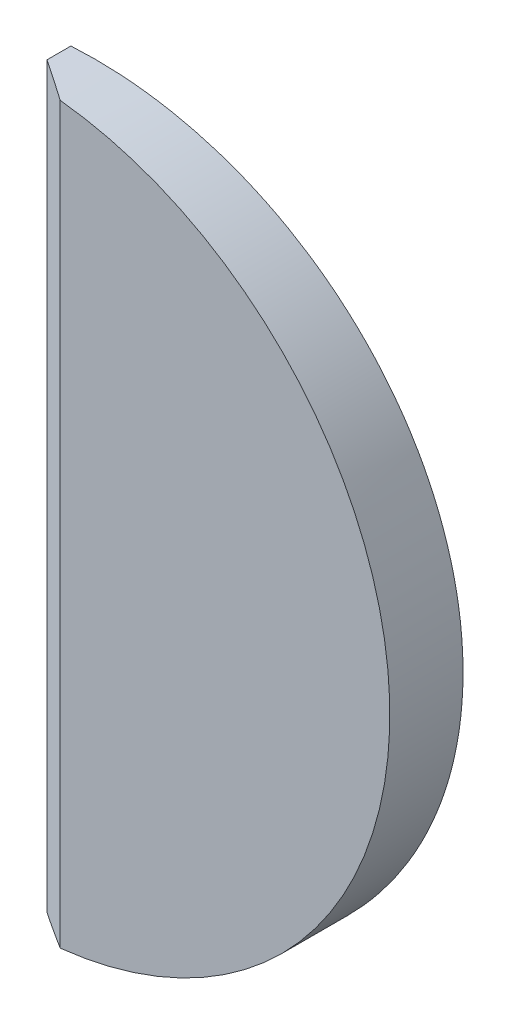
from build123d import *

# Parameters (mm, degrees)
SKETCH_6_R          = 15
CUT_EXTRUDE_1_DEPTH = 5
CHAMFER_1_SIZE      = 1
CHAMFER_1_SIZE2     = 1.5


with BuildPart() as part:
    # Эскиз5 → Повернуть1 (revolve)
    with BuildSketch(Plane(origin=(0, 0, 0), x_dir=(0, 0, -1), z_dir=(1, 0, 0))):
        with BuildLine():
            Line((-4, 0), (-4, 15))
            Line((-4, 15), (-2.303039929, 15))
            ThreePointArc((-2.303039929, 15), (-0.579113709, 7.587884964), (0, 0))
            Line((0, 0), (-4, 0))
        make_face()
    revolve(axis=Axis((0, 0, -1), (0, 0, 1)))

    # Эскиз6 → Вырез-Вытянуть1 (cut, through all)
    with BuildSketch(Plane.XY.offset(4)):
        Circle(SKETCH_6_R)
        with BuildLine():
            Line((-3, -14), (-3, 14))
            ThreePointArc((-3, 14), (11, 0), (-3, -14))
        make_face(mode=Mode.SUBTRACT)
    extrude(amount=-CUT_EXTRUDE_1_DEPTH, mode=Mode.SUBTRACT)

    # Фаска1
    chamfer_1_edges = [part.edges().sort_by_distance(p)[0] for p in [
        (-3, 0, 4),
    ]]
    chamfer_1_side = [part.faces().sort_by_distance(p)[0] for p in [
        (-3, 0, 2.321648578),
    ]]
    chamfer(chamfer_1_edges, length=CHAMFER_1_SIZE, length2=CHAMFER_1_SIZE2, reference=chamfer_1_side[0])


solid = part.part
